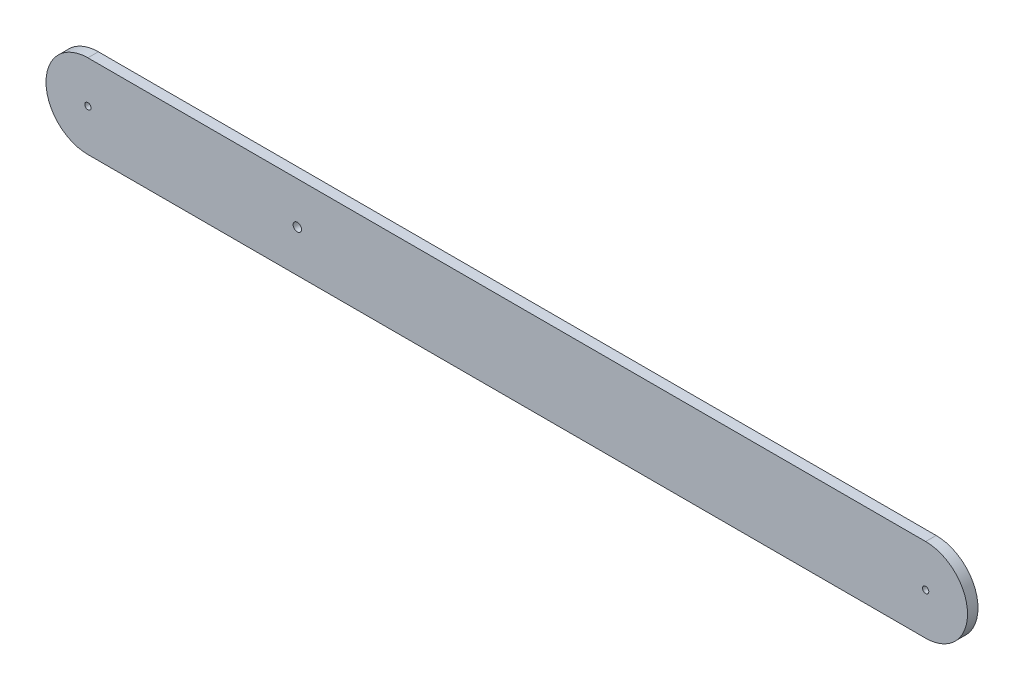
from build123d import *

# Parameters (mm, degrees)
SKETCH1_R           = 1.5
SKETCH1_R_2         = 2
BOSS_EXTRUDE1_DEPTH = 5


with BuildPart() as part:
    # Sketch1 → Boss-Extrude1 (new body)
    with BuildSketch(Plane.XY):
        with BuildLine():
            Line((-192.446633826, 20), (207.553366174, 20))
            ThreePointArc((207.553366174, 20), (227.553366174, 0), (207.553366174, -20))
            Line((207.553366174, -20), (-192.446633826, -20))
            ThreePointArc((-192.446633826, -20), (-212.446633826, 0), (-192.446633826, 20))
        make_face()
        with Locations((-192.446633826, 0)):
            Circle(SKETCH1_R, mode=Mode.SUBTRACT)
        with Locations((207.553366174, 0)):
            Circle(SKETCH1_R, mode=Mode.SUBTRACT)
        with Locations((-92.446633826, 0)):
            Circle(SKETCH1_R_2, mode=Mode.SUBTRACT)
    extrude(amount=BOSS_EXTRUDE1_DEPTH)


solid = part.part
